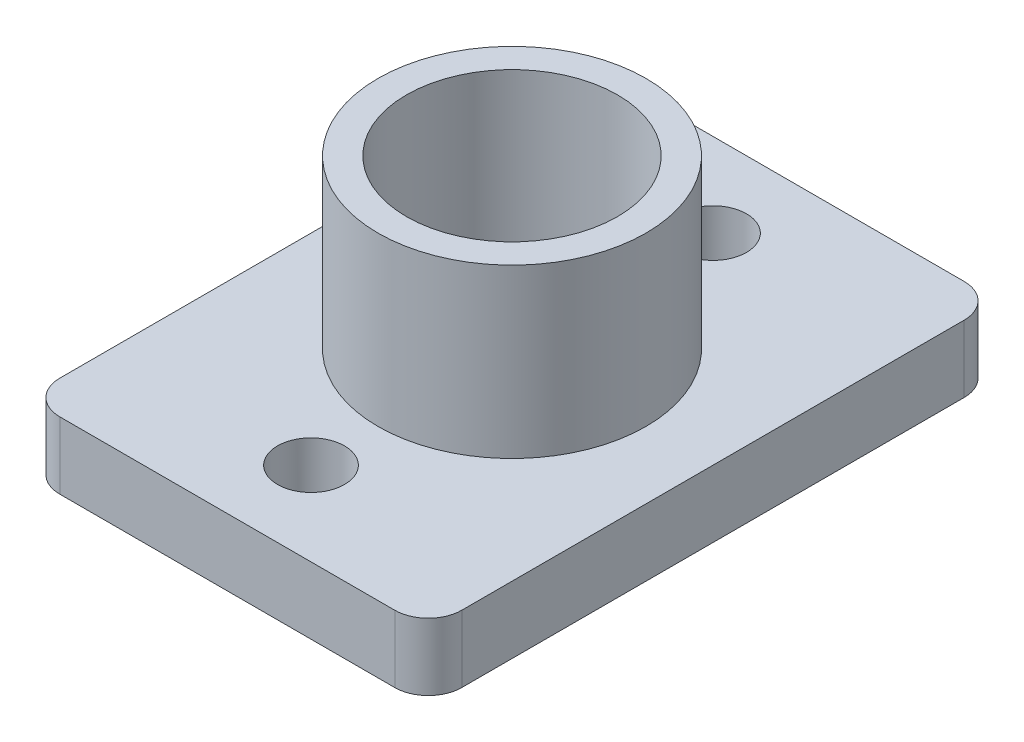
from build123d import *

# Parameters (mm, degrees)
SKETCH1_W               = 12
SKETCH1_H               = 17
MAIN_BODY_DEPTH         = 2
SKETCH2_R               = 4
SPACER_MOUNT_DEPTH      = 5
SKETCH3_R               = 3.15
SKETCH3_R_2             = 1
BOLT_SPACER_HOLES_DEPTH = 8
FILLET1_R               = 1


with BuildPart() as part:
    # Sketch1 → main_body (new body)
    with BuildSketch(Plane(origin=(0, 0, 0), x_dir=(1, 0, 0), z_dir=(0, 1, 0))):
        with Locations((6, 8.5)):
            Rectangle(SKETCH1_W, SKETCH1_H)
    extrude(amount=MAIN_BODY_DEPTH)

    # Sketch2 → spacer_mount (add)
    with BuildSketch(Plane(origin=(0, 2, 0), x_dir=(1, 0, 0), z_dir=(0, 1, 0))):
        with Locations((6, 8.5)):
            Circle(SKETCH2_R)
    extrude(amount=SPACER_MOUNT_DEPTH)

    # Sketch3 → bolt_spacer_holes (cut, through all)
    with BuildSketch(Plane(origin=(0, 7, 0), x_dir=(1, 0, 0), z_dir=(0, 1, 0))):
        with Locations((6, 8.5)):
            Circle(SKETCH3_R)
        with Locations((6, 14.5)):
            Circle(SKETCH3_R_2)
        with Locations((6, 2.5)):
            Circle(SKETCH3_R_2)
    extrude(amount=-BOLT_SPACER_HOLES_DEPTH, mode=Mode.SUBTRACT)

    # Fillet1
    fillet1_edges = [part.edges().sort_by_distance(p)[0] for p in [
        (0, 1, -17),
        (12, 1, -17),
        (12, 1, 0),
        (0, 1, 0),
    ]]
    fillet(fillet1_edges, radius=FILLET1_R)


solid = part.part
